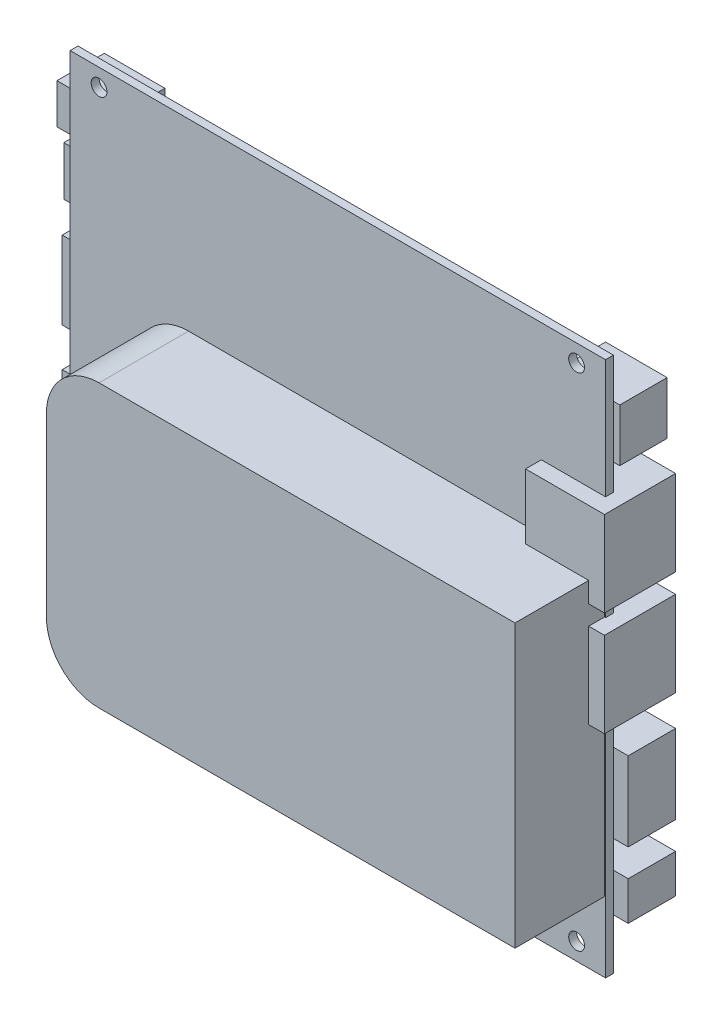
from build123d import *

# Parameters (mm, degrees)
SKETCH_1_W          = 101.7
SKETCH_1_H          = 101.7
EXTRUDE_1_DEPTH     = 1.5
SKETCH_2_R          = 1.5
CUT_EXTRUDE_1_DEPTH = 2.5
SKETCH_3_W          = 11.5
SKETCH_3_H          = 7.6
SKETCH_3_W_2        = 9
SKETCH_3_H_2        = 9.3
SKETCH_3_W_3        = 16.7
SKETCH_3_H_3        = 14.8
SKETCH_3_W_4        = 5.5
SKETCH_3_H_4        = 6
SKETCH_3_W_5        = 14
SKETCH_3_H_5        = 9.1
SKETCH_3_W_6        = 11.7
SKETCH_3_H_6        = 10
SKETCH_3_W_7        = 15
SKETCH_3_H_7        = 16.2
SKETCH_3_W_8        = 12.5
SKETCH_3_H_8        = 15
SKETCH_3_H_9        = 7.35
EXTRUDE_2_DEPTH     = 9
SKETCH_4_W          = 9
SKETCH_4_H          = 9.3
CUT_EXTRUDE_2_DEPTH = 4.1
SKETCH_5_W          = 16.7
SKETCH_5_H          = 14.8
CUT_EXTRUDE_3_DEPTH = 0.3
SKETCH_7_W          = 14
SKETCH_7_H          = 9.1
CUT_EXTRUDE_4_DEPTH = 3
SKETCH_8_W          = 15
SKETCH_8_H          = 16.2
EXTRUDE_4_DEPTH     = 13.5
SKETCH_9_W          = 89
SKETCH_9_H          = 53.5
EXTRUDE_5_DEPTH     = 17
FILLET_1_R          = 10


with BuildPart() as part:
    # 草图1 → 凸台-拉伸1 (new body)
    with BuildSketch(Plane.XY):
        Rectangle(SKETCH_1_W, SKETCH_1_H)
    extrude(amount=EXTRUDE_1_DEPTH)

    # 草图2 → 切除-拉伸1 (cut, through all)
    with BuildSketch(Plane(origin=(0, 0, 0), x_dir=(-1, 0, 0), z_dir=(0, 0, -1))):
        with Locations((-45.35, -47.55)):
            Circle(SKETCH_2_R)
        with Locations((45.35, -47.55)):
            Circle(SKETCH_2_R)
        with Locations((45.35, 47.55)):
            Circle(SKETCH_2_R)
        with Locations((-45.35, 47.55)):
            Circle(SKETCH_2_R)
    extrude(amount=-CUT_EXTRUDE_1_DEPTH, mode=Mode.SUBTRACT)

    # 草图3 → 凸台-拉伸2 (add)
    with BuildSketch(Plane(origin=(0, 0, 0), x_dir=(-1, 0, 0), z_dir=(0, 0, -1))):
        with Locations((49.1, 39.35)):
            Rectangle(SKETCH_3_W, SKETCH_3_H)
        with Locations((49.05, 28.95)):
            Rectangle(SKETCH_3_W_2, SKETCH_3_H_2)
        with Locations((45.5, 10.85)):
            Rectangle(SKETCH_3_W_3, SKETCH_3_H_3)
        with Locations((45.5, -11.28)):
            Rectangle(SKETCH_3_W_3, SKETCH_3_H_3)
        with Locations((51.3, -25.45)):
            Rectangle(SKETCH_3_W_4, SKETCH_3_H_4)
        with Locations((48.95, -36.4)):
            Rectangle(SKETCH_3_W_5, SKETCH_3_H_5)
        with Locations((-46.2, 38.26)):
            Rectangle(SKETCH_3_W_6, SKETCH_3_H_6)
        with Locations((-46.15, 20.19)):
            Rectangle(SKETCH_3_W_7, SKETCH_3_H_7)
        with Locations((-46.15, 0.32)):
            Rectangle(SKETCH_3_W_7, SKETCH_3_H_7)
        with Locations((-47.4, -21.15)):
            Rectangle(SKETCH_3_W_8, SKETCH_3_H_8)
        with Locations((-47.8, -37.545)):
            Rectangle(SKETCH_3_W_6, SKETCH_3_H_9)
    extrude(amount=EXTRUDE_2_DEPTH)

    # 草图4 → 切除-拉伸2 (cut)
    with BuildSketch(Plane(origin=(0, 0, -9), x_dir=(-1, 0, 0), z_dir=(0, 0, -1))):
        with Locations((49.05, 28.95)):
            Rectangle(SKETCH_4_W, SKETCH_4_H)
    extrude(amount=-CUT_EXTRUDE_2_DEPTH, mode=Mode.SUBTRACT)

    # 草图5 → 切除-拉伸3 (cut)
    with BuildSketch(Plane(origin=(0, 0, -9), x_dir=(-1, 0, 0), z_dir=(0, 0, -1))):
        with Locations((45.5, 10.85)):
            Rectangle(SKETCH_5_W, SKETCH_5_H)
        with Locations((45.5, -11.28)):
            Rectangle(SKETCH_5_W, SKETCH_5_H)
    extrude(amount=-CUT_EXTRUDE_3_DEPTH, mode=Mode.SUBTRACT)

    # 草图7 → 切除-拉伸4 (cut)
    with BuildSketch(Plane(origin=(0, 0, -9), x_dir=(-1, 0, 0), z_dir=(0, 0, -1))):
        with Locations((48.95, -36.4)):
            Rectangle(SKETCH_7_W, SKETCH_7_H)
    extrude(amount=-CUT_EXTRUDE_4_DEPTH, mode=Mode.SUBTRACT)

    # 草图8 → 凸台-拉伸4 (add)
    with BuildSketch(Plane(origin=(0, 0, -9), x_dir=(-1, 0, 0), z_dir=(0, 0, -1))):
        with Locations((-46.15, 0.32)):
            Rectangle(SKETCH_8_W, SKETCH_8_H)
        with Locations((-46.15, 20.19)):
            Rectangle(SKETCH_8_W, SKETCH_8_H)
    extrude(amount=-EXTRUDE_4_DEPTH)

    # 草图9 → 凸台-拉伸5 (add)
    with BuildSketch(Plane.XY.offset(1.5)):
        with Locations((6.15, -10.8)):
            Rectangle(SKETCH_9_W, SKETCH_9_H)
    extrude(amount=EXTRUDE_5_DEPTH)

    # 圆角1
    fillet_1_edges = [part.edges().sort_by_distance(p)[0] for p in [
        (-38.35, 15.95, 10),
        (-38.35, -37.55, 10),
    ]]
    fillet(fillet_1_edges, radius=FILLET_1_R)


solid = part.part
